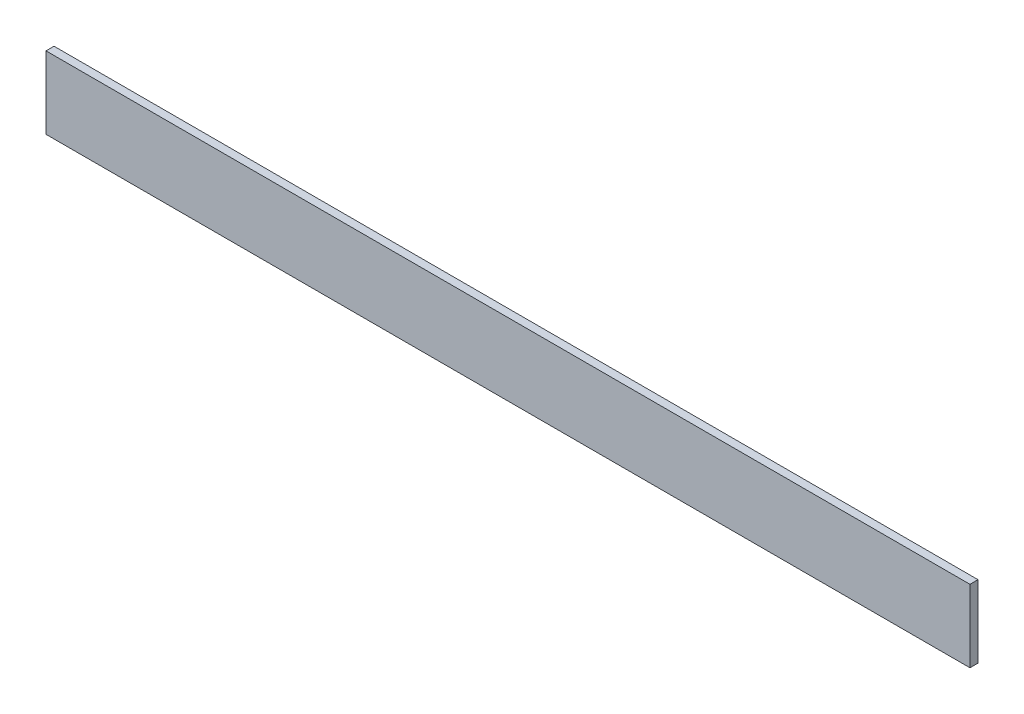
from build123d import *

# Parameters (mm, degrees)
SKETCH1_W           = 2300
SKETCH1_H           = 180
BOSS_EXTRUDE1_DEPTH = 10


with BuildPart() as part:
    # Sketch1 → Boss-Extrude1 (new body, symmetric)
    with BuildSketch(Plane.XY):
        Rectangle(SKETCH1_W, SKETCH1_H)
    extrude(amount=BOSS_EXTRUDE1_DEPTH, both=True)


solid = part.part
